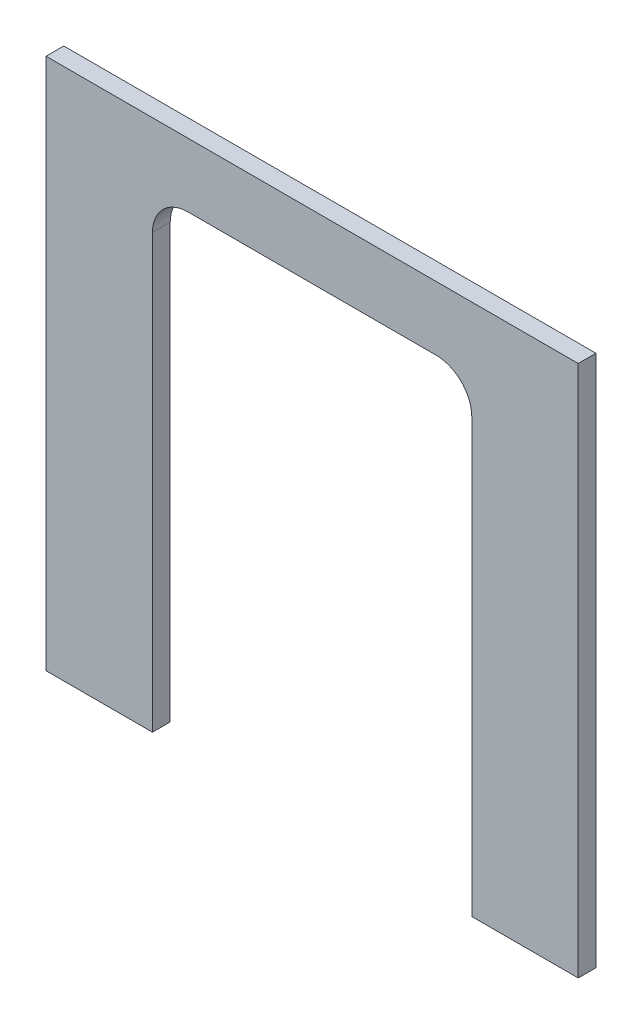
from build123d import *

# Parameters (mm, degrees)
BOSS_EXTRUDE1_DEPTH = 5


with BuildPart() as part:
    # Sketch1 → Boss-Extrude1 (new body)
    with BuildSketch(Plane.XY):
        with BuildLine():
            Line((45, -75), (45, 47))
            ThreePointArc((45, 47), (42.071067812, 54.071067812), (35, 57))
            Line((35, 57), (-35, 57))
            ThreePointArc((-35, 57), (-42.071067812, 54.071067812), (-45, 47))
            Line((-45, 47), (-45, -75))
            Line((-45, -75), (-75, -75))
            Line((-75, -75), (-75, 75))
            Line((-75, 75), (75, 75))
            Line((75, 75), (75, -75))
            Line((75, -75), (45, -75))
        make_face()
    extrude(amount=BOSS_EXTRUDE1_DEPTH)


solid = part.part
